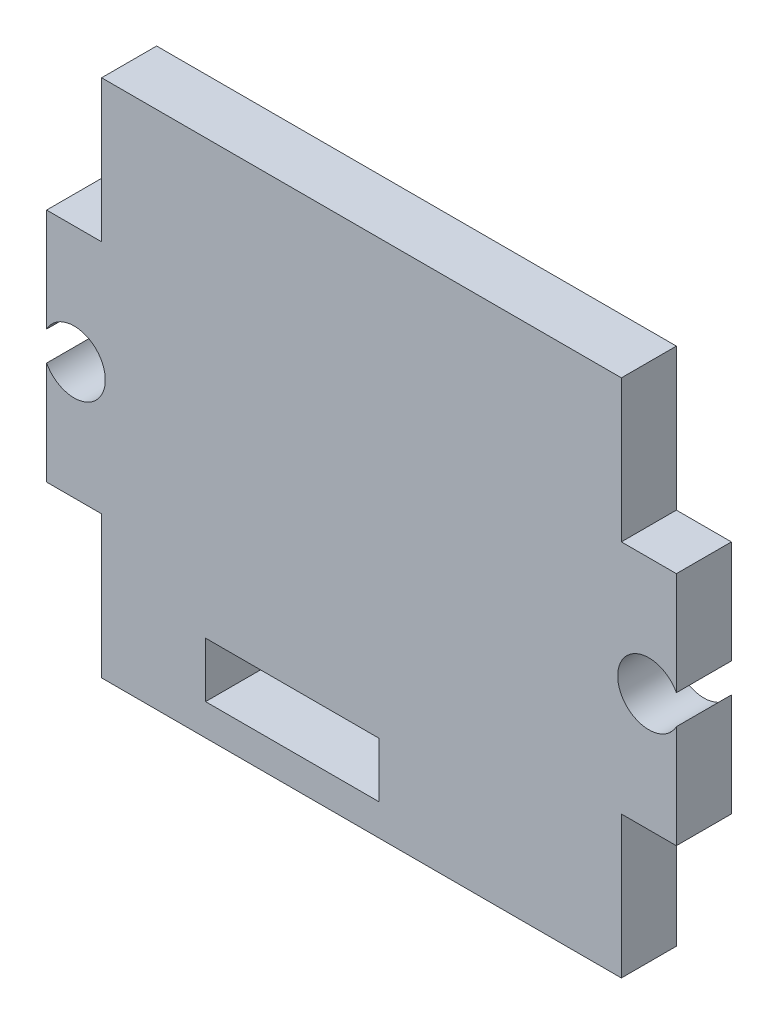
from build123d import *

# Parameters (mm, degrees)
SKETCH1_W           = 10
SKETCH1_H           = 3.175
BOSS_EXTRUDE4_DEPTH = 3.175


with BuildPart() as part:
    # Sketch1 → Boss-Extrude4 (new body)
    with BuildSketch(Plane.XY):
        with BuildLine():
            Line((-33.68050161, 39.580766243), (-36.85550161, 39.580766243))
            Line((-36.85550161, 39.580766243), (-36.85550161, 33.629202304))
            ThreePointArc((-36.85550161, 33.629202304), (-33.46800161, 32.780766243), (-36.85550161, 31.932330182))
            Line((-36.85550161, 31.932330182), (-36.85550161, 25.980766243))
            Line((-36.85550161, 25.980766243), (-33.68050161, 25.980766243))
            Line((-33.68050161, 25.980766243), (-33.68050161, 17.780766243))
            Line((-33.68050161, 17.780766243), (-3.68050161, 17.780766243))
            Line((-3.68050161, 17.780766243), (-3.68050161, 25.980766243))
            Line((-3.68050161, 25.980766243), (-0.50550161, 25.980766243))
            Line((-0.50550161, 25.980766243), (-0.50550161, 31.932330182))
            ThreePointArc((-0.50550161, 31.932330182), (-3.89300161, 32.780766243), (-0.50550161, 33.629202304))
            Line((-0.50550161, 33.629202304), (-0.50550161, 39.580766243))
            Line((-0.50550161, 39.580766243), (-3.68050161, 39.580766243))
            Line((-3.68050161, 39.580766243), (-3.68050161, 47.780766243))
            Line((-3.68050161, 47.780766243), (-33.68050161, 47.780766243))
            Line((-33.68050161, 47.780766243), (-33.68050161, 39.580766243))
        make_face()
        with Locations((-22.68050161, 21.182701237)):
            Rectangle(SKETCH1_W, SKETCH1_H, mode=Mode.SUBTRACT)
    extrude(amount=BOSS_EXTRUDE4_DEPTH)


solid = part.part
